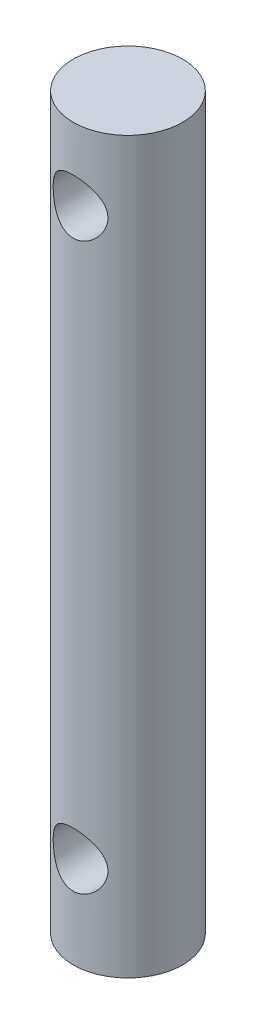
from build123d import *

# Parameters (mm, degrees)
SKETCH_1_R               = 3
EXTRUDE_1_DEPTH          = 20
SKETCH_2_R               = 1.5
CUT_EXTRUDE_1_DEPTH      = 4
CUT_EXTRUDE_1_DEPTH_BACK = 4


with BuildPart() as part:
    # 草圖1 → 填料-伸長1 (new body, symmetric)
    with BuildSketch(Plane(origin=(0, 0, 0), x_dir=(1, 0, 0), z_dir=(0, 1, 0))):
        Circle(SKETCH_1_R)
    extrude(amount=EXTRUDE_1_DEPTH, both=True)

    # 草圖2 → 除料-伸長1 (cut, two sides)
    with BuildSketch(Plane.XY) as cut_extrude_1_sk:
        with Locations((0, 16)):
            Circle(SKETCH_2_R)
        with Locations((0, -15)):
            Circle(SKETCH_2_R)
    extrude(amount=CUT_EXTRUDE_1_DEPTH, mode=Mode.SUBTRACT)
    extrude(cut_extrude_1_sk.sketch, amount=-CUT_EXTRUDE_1_DEPTH_BACK, mode=Mode.SUBTRACT)


solid = part.part
